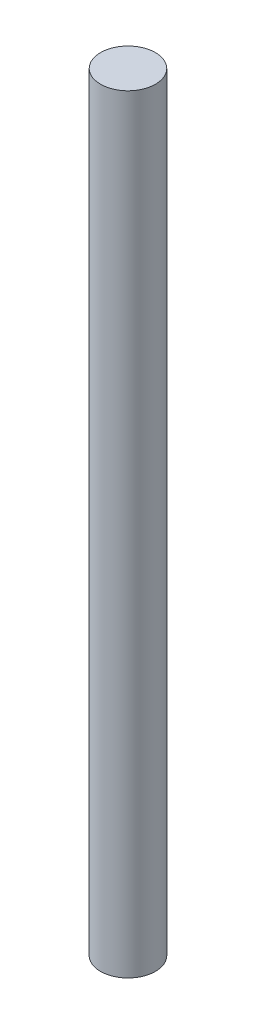
from build123d import *

# Parameters (mm, degrees)
SKETCH1_R           = 3.175
BOSS_EXTRUDE1_DEPTH = 88.9


with BuildPart() as part:
    # Sketch1 → Boss-Extrude1 (new body)
    with BuildSketch(Plane(origin=(0, 0, 0), x_dir=(1, 0, 0), z_dir=(0, 1, 0))):
        Circle(SKETCH1_R)
    extrude(amount=BOSS_EXTRUDE1_DEPTH)


solid = part.part
